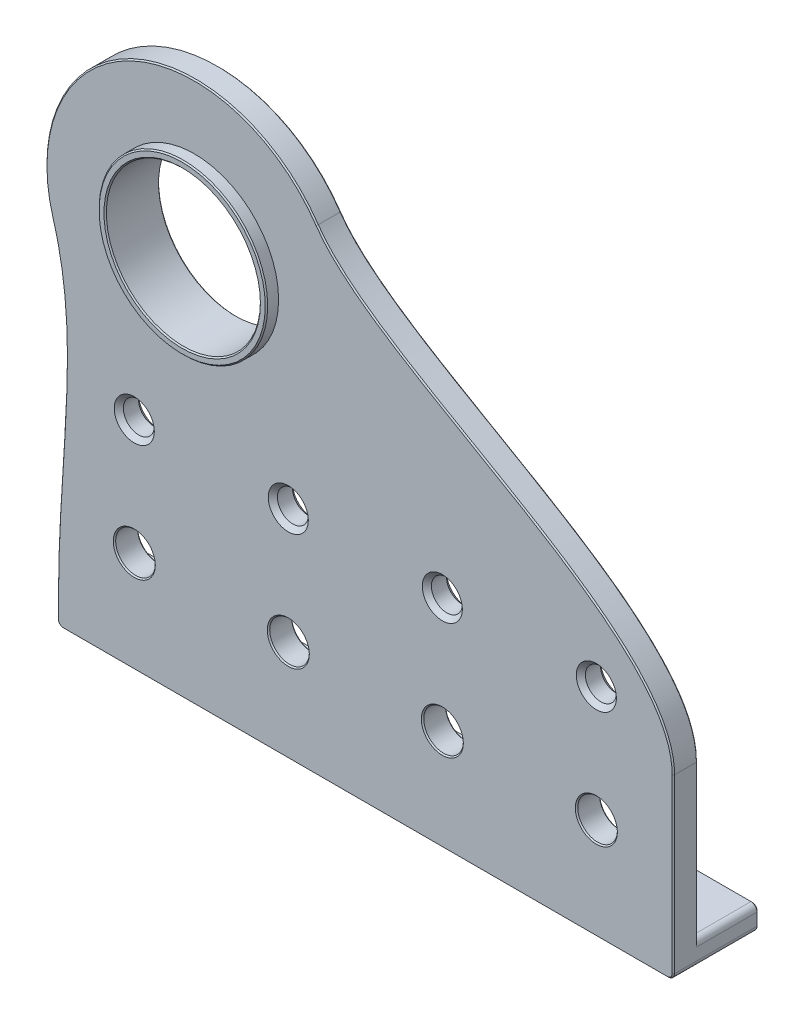
from build123d import *

# Parameters (mm, degrees)
MAIN_FEATURES_SKETCH_R           = 24.5
MAIN_FEATURES_SKETCH_R_2         = 15.75
MAIN_FEATURES_SKETCH_R_3         = 12.7
MAIN_FEATURES_SKETCH_R_4         = 13.9
OUTER_RING_DEPTH                 = 4
MAIN_FEATURES_SKETCH_3_R         = 15.75
MAIN_FEATURES_SKETCH_3_R_2       = 13.9
MAIN_FEATURES_SKETCH_3_R_3       = 12.7
INNER_RING_DEPTH                 = 3
MAIN_FEATURES_SKETCH_4_R         = 13.9
MAIN_FEATURES_SKETCH_4_R_2       = 12.7
SUPPORT_RING_DEPTH               = 6
MAIN_FEATURES_SKETCH_5_R         = 3.2639
MAIN_FEATURES_SKETCH_5_W         = 101.6
MAIN_FEATURES_SKETCH_5_H         = 4
MAIN_FEATURES_SKETCH_5_W_2       = 69.85
MAIN_FEATURES_SKETCH_5_W_3       = 19.05
MAIN_FEATURES_SKETCH_5_W_4       = 12.7
PLATE_DEPTH                      = 4
MAIN_FEATURES_SKETCH_6_W         = 12.7
MAIN_FEATURES_SKETCH_6_H         = 4
MAIN_FEATURES_SKETCH_6_W_2       = 69.85
LEDGE_DEPTH                      = 10
F_1_4_20_TAPPED_HOLE1_AT_2_COUNT = 2
F_1_4_20_TAPPED_HOLE1_AT_2_PITCH = 25.4
F_1_4_20_TAPPED_HOLE1_AT_3_COUNT = 2
F_1_4_20_TAPPED_HOLE1_AT_3_PITCH = 76.2
F_1_4_20_TAPPED_HOLE1_AT_4_COUNT = 2
F_1_4_20_TAPPED_HOLE1_AT_4_PITCH = 50.8
FILLET1_R                        = 1
CHAMFER1_SIZE                    = 0.2


with BuildPart() as part:
    # main_features_sketch → outer_ring (new body)
    with BuildSketch(Plane.XY):
        with Locations((-10, 0)):
            Circle(MAIN_FEATURES_SKETCH_R)
        with Locations((-10, 0)):
            Circle(MAIN_FEATURES_SKETCH_R_2, mode=Mode.SUBTRACT)
        with Locations((-10, 0)):
            Circle(MAIN_FEATURES_SKETCH_R_2)
        with Locations((-10, 0)):
            Circle(MAIN_FEATURES_SKETCH_R_3, mode=Mode.SUBTRACT)
        with Locations((-10, 0)):
            Circle(MAIN_FEATURES_SKETCH_R_4)
        with Locations((-10, 0)):
            Circle(MAIN_FEATURES_SKETCH_R_3, mode=Mode.SUBTRACT)
    extrude(amount=OUTER_RING_DEPTH)

    # main_features_sketch_3 → inner_ring (add)
    with BuildSketch(Plane.XY):
        with Locations((-10, 0)):
            Circle(MAIN_FEATURES_SKETCH_3_R)
        with Locations((-10, 0)):
            Circle(MAIN_FEATURES_SKETCH_3_R_2, mode=Mode.SUBTRACT)
        with Locations((-10, 0)):
            Circle(MAIN_FEATURES_SKETCH_3_R_2)
        with Locations((-10, 0)):
            Circle(MAIN_FEATURES_SKETCH_3_R_3, mode=Mode.SUBTRACT)
    extrude(amount=-INNER_RING_DEPTH)

    # main_features_sketch_4 → support_ring (add)
    with BuildSketch(Plane.XY):
        with Locations((-10, 0)):
            Circle(MAIN_FEATURES_SKETCH_4_R)
        with Locations((-10, 0)):
            Circle(MAIN_FEATURES_SKETCH_4_R_2, mode=Mode.SUBTRACT)
    extrude(amount=SUPPORT_RING_DEPTH)

    # groove_sketch → groove (revolve, cut)
    with BuildSketch(Plane(origin=(-10, 0, 0), x_dir=(0, 0, -1), z_dir=(1, 0, 0)), mode=Mode.PRIVATE) as groove_sk:
        Polygon((2.35, 15.75), (1.65, 15.05), (0.95, 15.75), align=None)
    revolve(groove_sk.sketch.rotate(Axis((-10, 0, 4), (0, 0, -1)), 90), axis=Axis((-10, 0, 4), (0, 0, -1)), mode=Mode.SUBTRACT)

    # main_features_sketch_5 → plate (add)
    with BuildSketch(Plane.XY):
        with BuildLine():
            add(Edge.make_bspline(
                [(-32.6, -60.8), (-32.6, -39.723627729), (-28.738697218, -22.987442245), (-33.489342322, -6.96425138)],
                knots=[0, 0, 0, 0, 1, 1, 1, 1], degree=3))
            Line((-32.6, -60.8), (37.25, -60.8))
            Line((37.25, -60.8), (56.3, -60.8))
            Line((56.3, -60.8), (69, -60.8))
            Line((69, -60.8), (69, -35.4))
            add(Edge.make_bspline(
                [(69, -35.4), (69, -15.705164825), (20.577875926, -1.371414224), (10.248802697, 13.792606329)],
                knots=[0, 0, 0, 0, 1, 1, 1, 1], degree=3))
            ThreePointArc((10.248802697, 13.792606329), (13.413091061, 7.216451134), (14.5, 0))
            ThreePointArc((14.5, 0), (-6.481398494, -24.246019126), (-33.489342322, -6.96425138))
        make_face()
        with Locations((-19.9, -48.1)):
            Circle(MAIN_FEATURES_SKETCH_5_R, mode=Mode.SUBTRACT)
        with Locations((5.5, -48.1)):
            Circle(MAIN_FEATURES_SKETCH_5_R, mode=Mode.SUBTRACT)
        with Locations((30.9, -48.1)):
            Circle(MAIN_FEATURES_SKETCH_5_R, mode=Mode.SUBTRACT)
        with Locations((56.3, -48.1)):
            Circle(MAIN_FEATURES_SKETCH_5_R, mode=Mode.SUBTRACT)
        with Locations((18.2, -62.8)):
            Rectangle(MAIN_FEATURES_SKETCH_5_W, MAIN_FEATURES_SKETCH_5_H)
        with Locations((2.325, -62.8)):
            Rectangle(MAIN_FEATURES_SKETCH_5_W_2, MAIN_FEATURES_SKETCH_5_H)
        with Locations((46.775, -62.8)):
            Rectangle(MAIN_FEATURES_SKETCH_5_W_3, MAIN_FEATURES_SKETCH_5_H)
        with Locations((62.65, -62.8)):
            Rectangle(MAIN_FEATURES_SKETCH_5_W_4, MAIN_FEATURES_SKETCH_5_H)
    extrude(amount=PLATE_DEPTH)

    # main_features_sketch_6 → ledge (add)
    with BuildSketch(Plane.XY):
        with Locations((62.65, -62.8)):
            Rectangle(MAIN_FEATURES_SKETCH_6_W, MAIN_FEATURES_SKETCH_6_H)
        with Locations((2.325, -62.8)):
            Rectangle(MAIN_FEATURES_SKETCH_6_W_2, MAIN_FEATURES_SKETCH_6_H)
    extrude(amount=-LEDGE_DEPTH)

    # Sketch2 → 1_4-20 Tapped Hole1 (revolve, cut)
    with BuildSketch(Plane(origin=(56.3, -29.05, 4), x_dir=(0, -1, 0), z_dir=(1, 0, 0))):
        Polygon((0, 0), (0, 4), (3.302, 4), (2.5527, 3.2507), (2.5527, 0.7493), (3.302, 0), align=None)
    f_1_4_20_tapped_hole1 = revolve(axis=Axis((56.3, -29.05, 10.35), (0, 0, -1)), mode=Mode.SUBTRACT)

    # 1_4-20 Tapped Hole1 at 2: 1_4-20 Tapped Hole1 ×2
    with Locations(*[(-i * F_1_4_20_TAPPED_HOLE1_AT_2_PITCH, 0, 0) for i in range(1, F_1_4_20_TAPPED_HOLE1_AT_2_COUNT)]):
        add(f_1_4_20_tapped_hole1, mode=Mode.SUBTRACT)

    # 1_4-20 Tapped Hole1 at 3: 1_4-20 Tapped Hole1 ×2
    with Locations(*[(-i * F_1_4_20_TAPPED_HOLE1_AT_3_PITCH, 0, 0) for i in range(1, F_1_4_20_TAPPED_HOLE1_AT_3_COUNT)]):
        add(f_1_4_20_tapped_hole1, mode=Mode.SUBTRACT)

    # 1_4-20 Tapped Hole1 at 4: 1_4-20 Tapped Hole1 ×2
    with Locations(*[(-i * F_1_4_20_TAPPED_HOLE1_AT_4_PITCH, 0, 0) for i in range(1, F_1_4_20_TAPPED_HOLE1_AT_4_COUNT)]):
        add(f_1_4_20_tapped_hole1, mode=Mode.SUBTRACT)

    # Fillet1
    fillet1_edges = [part.edges().sort_by_distance(p)[0] for p in [
        (69, -64.8, -3),
        (-32.6, -64.8, -3),
        (56.3, -64.8, -5),
        (56.3, -60.8, -5),
        (69, -60.8, -5),
        (37.25, -64.8, -5),
        (-32.6, -60.8, -5),
        (37.25, -60.8, -5),
    ]]
    fillet(fillet1_edges, radius=FILLET1_R)

    # Chamfer1
    chamfer1_edges = [part.edges().sort_by_distance(p)[0] for p in [
        (-23.9, 0, 6),
        (-22.7, 0, 6),
        (-25.75, 0, -3),
        (-22.7, 0, -3),
        (-23.1639, -48.1, 0),
        (-23.1639, -48.1, 4),
        (2.2361, -48.1, 0),
        (2.2361, -48.1, 4),
        (27.6361, -48.1, 0),
        (27.6361, -48.1, 4),
        (53.0361, -48.1, 0),
        (53.0361, -48.1, 4),
        (68.707106781, -61.092893219, -10),
        (62.65, -60.8, -10),
        (56.592893219, -61.092893219, -10),
        (56.3, -62.8, -10),
        (56.592893219, -64.507106781, -10),
        (62.65, -64.8, -10),
        (68.707106781, -64.507106781, -10),
        (69, -62.8, -10),
        (-32.307106781, -61.092893219, -10),
        (-32.6, -62.8, -10),
        (-32.307106781, -64.507106781, -10),
        (2.325, -64.8, -10),
        (36.957106781, -64.507106781, -10),
        (37.25, -62.8, -10),
        (36.957106781, -61.092893219, -10),
        (2.325, -60.8, -10),
        (68.707106781, -64.507106781, 4),
        (18.2, -64.8, 4),
        (69, -49.6, 4),
        (-32.307106781, -64.507106781, 4),
        (42.397221588, -8.455112608, 4),
        (42.397221588, -8.455112608, 0),
        (-32.6, -62.3, 4),
        (-20.504144885, 22.133977054, 4),
        (-20.504144885, 22.133977054, 0),
        (-31.34637018, -33.788834835, 4),
        (-31.34637018, -33.788834835, 0),
        (46.775, -64.8, 0),
        (69, -48.6, 0),
        (-32.6, -61.3, 0),
    ]]
    chamfer(chamfer1_edges, length=CHAMFER1_SIZE)


solid = part.part
